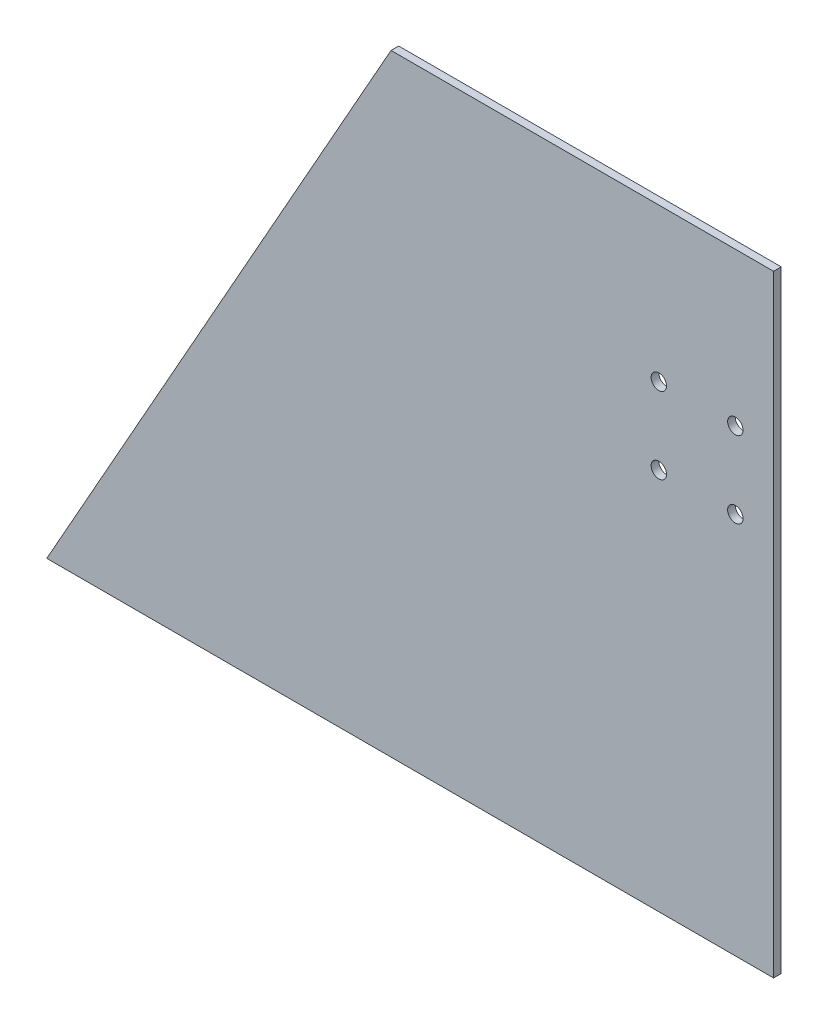
from build123d import *

# Parameters (mm, degrees)
BOSS_EXTRUDE1_DEPTH    = 2.54
F_10_CLEARANCE_HOLE1_D = 5.1054


with BuildPart() as part:
    # Sketch1 → Boss-Extrude1 (new body)
    with BuildSketch(Plane.XY):
        Polygon((0, 0), (241.3, 0), (241.3, 203.2), (114.3, 203.2), align=None)
    extrude(amount=BOSS_EXTRUDE1_DEPTH)

    # #10 Clearance Hole1 (through all)
    with Locations(Plane.XY.offset(2.54)):
        with Locations((203.2, 152.4), (228.6, 127), (203.2, 127), (228.6, 152.4)):
            Hole(F_10_CLEARANCE_HOLE1_D / 2)


solid = part.part
